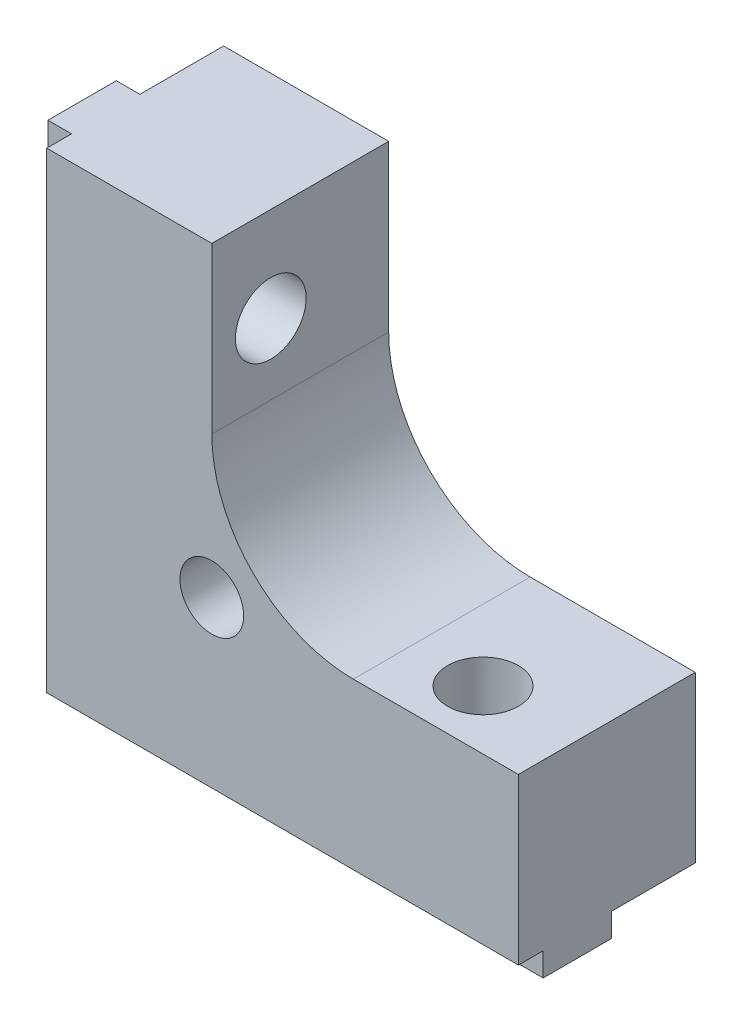
from build123d import *

# Parameters (mm, degrees)
MAIN_DEPTH                         = 10
ESQUISSE4_W                        = 2.9
ESQUISSE4_H                        = 20
MAKERBEAMFIXVERTICAL_DEPTH         = 1
MAKERBEAMVERTICALHOLE_DEPTH        = 31
MAKERBEAMVERTICALHOLE_DEPTH_BACK   = 31
ESQUISSE2_R                        = 1.5
ESQUISSE5_W                        = 20
ESQUISSE5_H                        = 2.9
MAKERBEAMFIXHORIZONTAL_DEPTH       = 1
MAKERBEAMHORIZONTALHOLE_DEPTH      = 31
MAKERBEAMHORIZONTALHOLE_DEPTH_BACK = 31
ESQUISSE3_R                        = 1.5
SKETCH1_R                          = 1.35
WINDOWFIXHOLE_DEPTH                = 31
SKETCH2_W                          = 2.5
SKETCH2_H                          = 20
WINDOW_DEPTH                       = 31


with BuildPart() as part:
    # Esquisse1 → Main (new body)
    with BuildSketch(Plane.XY):
        with BuildLine():
            Line((0, 0), (20, 0))
            Line((20, 0), (20, 7))
            Line((20, 7), (13, 7))
            ThreePointArc((13, 7), (8.757359313, 8.757359313), (7, 13))
            Line((7, 13), (7, 20))
            Line((7, 20), (0, 20))
            Line((0, 20), (0, 0))
        make_face()
    extrude(amount=MAIN_DEPTH)

    # Esquisse4 → MakerBeamFixVertical (add)
    with BuildSketch(Plane.ZY):
        with Locations((5, 10)):
            Rectangle(ESQUISSE4_W, ESQUISSE4_H)
    extrude(amount=MAKERBEAMFIXVERTICAL_DEPTH)

    # Esquisse2 → MakerBeamVerticalHole (cut, two sides: drawn at the far end of the back side and taken through both)
    with BuildSketch(Plane.ZY.offset(-MAKERBEAMVERTICALHOLE_DEPTH_BACK)):
        with Locations(Location((5, 16, 0), (0, 0, 270))):
            Circle(ESQUISSE2_R)
    extrude(amount=MAKERBEAMVERTICALHOLE_DEPTH + MAKERBEAMVERTICALHOLE_DEPTH_BACK, mode=Mode.SUBTRACT)

    # Esquisse5 → MakerBeamFixHorizontal (add)
    with BuildSketch(Plane(origin=(0, 0, 0), x_dir=(-1, 0, 0), z_dir=(0, -1, 0))):
        with Locations((-10, -5)):
            Rectangle(ESQUISSE5_W, ESQUISSE5_H)
    extrude(amount=MAKERBEAMFIXHORIZONTAL_DEPTH)

    # Esquisse3 → MakerBeamHorizontalHole (cut, two sides: drawn at the far end of the back side and taken through both)
    with BuildSketch(Plane.XZ.offset(-MAKERBEAMHORIZONTALHOLE_DEPTH_BACK)):
        with Locations(Location((16, 5, 0), (0, 0, 270))):
            Circle(ESQUISSE3_R)
    extrude(amount=MAKERBEAMHORIZONTALHOLE_DEPTH + MAKERBEAMHORIZONTALHOLE_DEPTH_BACK, mode=Mode.SUBTRACT)

    # Sketch1 → WindowFixHole (cut, through all)
    with BuildSketch(Plane.XY.offset(10)):
        with Locations((7, 7)):
            Circle(SKETCH1_R)
    extrude(amount=-WINDOWFIXHOLE_DEPTH, mode=Mode.SUBTRACT)

    # Sketch2 → Window (cut, through all)
    with BuildSketch(Plane.ZY):
        with Locations((8.75, 10)):
            Rectangle(SKETCH2_W, SKETCH2_H)
    extrude(amount=-WINDOW_DEPTH, mode=Mode.SUBTRACT)


solid = part.part
